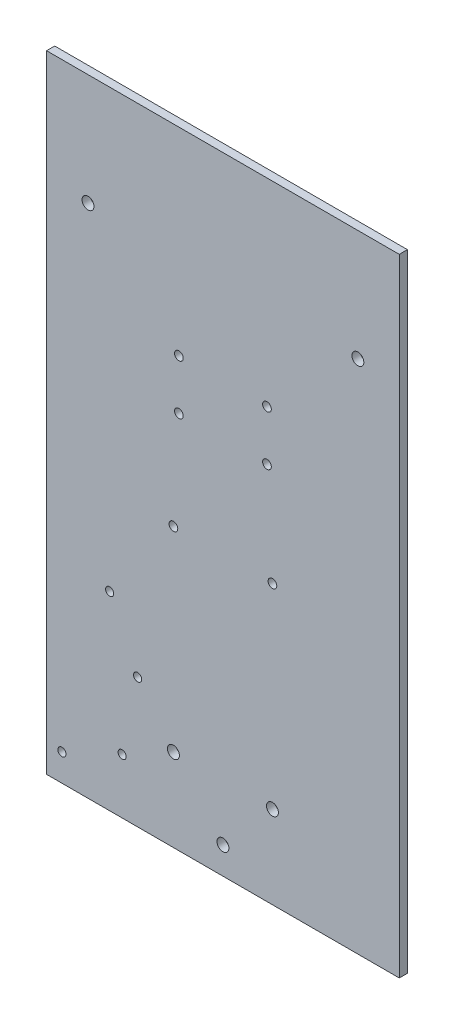
from build123d import *

# Parameters (mm, degrees)
SKETCH_1_W               = 150
SKETCH_1_H               = 231
EXTRUDE_1_DEPTH          = 12.5
CUT_EXTRUDE_1_DEPTH      = 10.5
SKETCH_4_R               = 2.2
CUT_EXTRUDE_3_DEPTH      = 1
CUT_EXTRUDE_3_DEPTH_BACK = 13.5
SKETCH_5_R               = 2.2
SKETCH_5_R_2             = 1.6
SKETCH_5_R_3             = 1.5
CUT_EXTRUDE_4_DEPTH      = 13.5
SKETCH_6_R               = 1.5
CUT_EXTRUDE_5_DEPTH      = 10
SKETCH_3_R               = 1.6
CUT_EXTRUDE_6_DEPTH      = 10
SKETCH_7_W               = 10
SKETCH_7_H               = 231
CUT_EXTRUDE_7_DEPTH      = 13.5
SKETCH_8_W               = 10
SKETCH_8_H               = 231
CUT_EXTRUDE_8_DEPTH      = 13.5
SKETCH_9_W               = 43
SKETCH_9_H               = 102
EXTRUDE_2_DEPTH          = 10.5
SKETCH_10_R              = 1.6
CUT_EXTRUDE_9_DEPTH      = 30
SKETCH_11_W              = 130
SKETCH_11_H              = 231
CUT_EXTRUDE_10_DEPTH     = 9.5


with BuildPart() as part:
    # ｽｹｯﾁ1 → ﾎﾞｽ - 押し出し1 (new body)
    with BuildSketch(Plane.XY):
        Rectangle(SKETCH_1_W, SKETCH_1_H)
    extrude(amount=EXTRUDE_1_DEPTH)

    # ｽｹｯﾁ2 → ｶｯﾄ - 押し出し1 (cut)
    with BuildSketch(Plane.XY.offset(12.5)):
        Polygon((0, 115.5), (21.5, 115.5), (21.5, 13.5), (-21.5, 13.5), (-21.5, 115.5), align=None)
    extrude(amount=-CUT_EXTRUDE_1_DEPTH, mode=Mode.SUBTRACT)

    # ｽｹｯﾁ4 → ｶｯﾄ - 押し出し3 (cut, two sides)
    with BuildSketch(Plane.XY.offset(12.5)) as cut_extrude_3_sk:
        with Locations((-49.73, 74.5)):
            Circle(SKETCH_4_R)
        with Locations((49.73, 74.5)):
            Circle(SKETCH_4_R)
    extrude(amount=CUT_EXTRUDE_3_DEPTH, mode=Mode.SUBTRACT)
    extrude(cut_extrude_3_sk.sketch, amount=-CUT_EXTRUDE_3_DEPTH_BACK, mode=Mode.SUBTRACT)

    # ｽｹｯﾁ5 → ｶｯﾄ - 押し出し4 (cut, through all)
    with BuildSketch(Plane.XY.offset(12.5)):
        with Locations((18.25, -85)):
            Circle(SKETCH_5_R)
        with Locations((18.25, -12.95)):
            Circle(SKETCH_5_R_2)
        with Locations((-41.75, -45.48)):
            Circle(SKETCH_5_R_3)
        with Locations((-31.45, -67.68)):
            Circle(SKETCH_5_R_3)
        with Locations((-18.25, -85)):
            Circle(SKETCH_5_R)
        with Locations((-18.25, -12.95)):
            Circle(SKETCH_5_R_2)
        with Locations((0, -105.5)):
            Circle(SKETCH_5_R)
        with Locations((-59.34, -105.5)):
            Circle(SKETCH_5_R_3)
        with Locations((-37.14, -95.2)):
            Circle(SKETCH_5_R_3)
    extrude(amount=-CUT_EXTRUDE_4_DEPTH, mode=Mode.SUBTRACT)

    # ｽｹｯﾁ6 → ｶｯﾄ - 押し出し5 (cut)
    with BuildSketch(Plane.XY.offset(2)):
        with Locations((-12.5, 105.5)):
            Circle(SKETCH_6_R)
        with Locations((12.5, 105.5)):
            Circle(SKETCH_6_R)
    extrude(amount=-CUT_EXTRUDE_5_DEPTH, mode=Mode.SUBTRACT)

    # ｽｹｯﾁ3 → ｶｯﾄ - 押し出し6 (cut)
    with BuildSketch(Plane.XY.offset(2)):
        with Locations((-16.23, 42.5)):
            Circle(SKETCH_3_R)
        with Locations((16.23, 42.5)):
            Circle(SKETCH_3_R)
        with Locations((-16.23, 24.1)):
            Circle(SKETCH_3_R)
        with Locations((16.23, 24.1)):
            Circle(SKETCH_3_R)
    extrude(amount=-CUT_EXTRUDE_6_DEPTH, mode=Mode.SUBTRACT)

    # ｽｹｯﾁ7 → ｶｯﾄ - 押し出し7 (cut, through all)
    with BuildSketch(Plane.XY.offset(12.5)):
        with Locations((-70, 0)):
            Rectangle(SKETCH_7_W, SKETCH_7_H)
    extrude(amount=-CUT_EXTRUDE_7_DEPTH, mode=Mode.SUBTRACT)

    # ｽｹｯﾁ8 → ｶｯﾄ - 押し出し8 (cut, through all)
    with BuildSketch(Plane.XY.offset(12.5)):
        with Locations((70, 0)):
            Rectangle(SKETCH_8_W, SKETCH_8_H)
    extrude(amount=-CUT_EXTRUDE_8_DEPTH, mode=Mode.SUBTRACT)

    # ｽｹｯﾁ9 → ﾎﾞｽ - 押し出し2 (add)
    with BuildSketch(Plane.XY.offset(2)):
        with Locations((0, 64.5)):
            Rectangle(SKETCH_9_W, SKETCH_9_H)
    extrude(amount=EXTRUDE_2_DEPTH)

    # ｽｹｯﾁ10 → ｶｯﾄ - 押し出し9 (cut)
    with BuildSketch(Plane(origin=(0, 0, 0), x_dir=(-1, 0, 0), z_dir=(0, 0, -1))):
        with Locations((-16.23, 24.1)):
            Circle(SKETCH_10_R)
        with Locations((-16.23, 42.5)):
            Circle(SKETCH_10_R)
        with Locations((16.23, 42.5)):
            Circle(SKETCH_10_R)
        with Locations((16.23, 24.1)):
            Circle(SKETCH_10_R)
    extrude(amount=-CUT_EXTRUDE_9_DEPTH, mode=Mode.SUBTRACT)

    # ｽｹｯﾁ11 → ｶｯﾄ - 押し出し10 (cut)
    with BuildSketch(Plane.XY.offset(12.5)):
        Rectangle(SKETCH_11_W, SKETCH_11_H)
    extrude(amount=-CUT_EXTRUDE_10_DEPTH, mode=Mode.SUBTRACT)


solid = part.part
